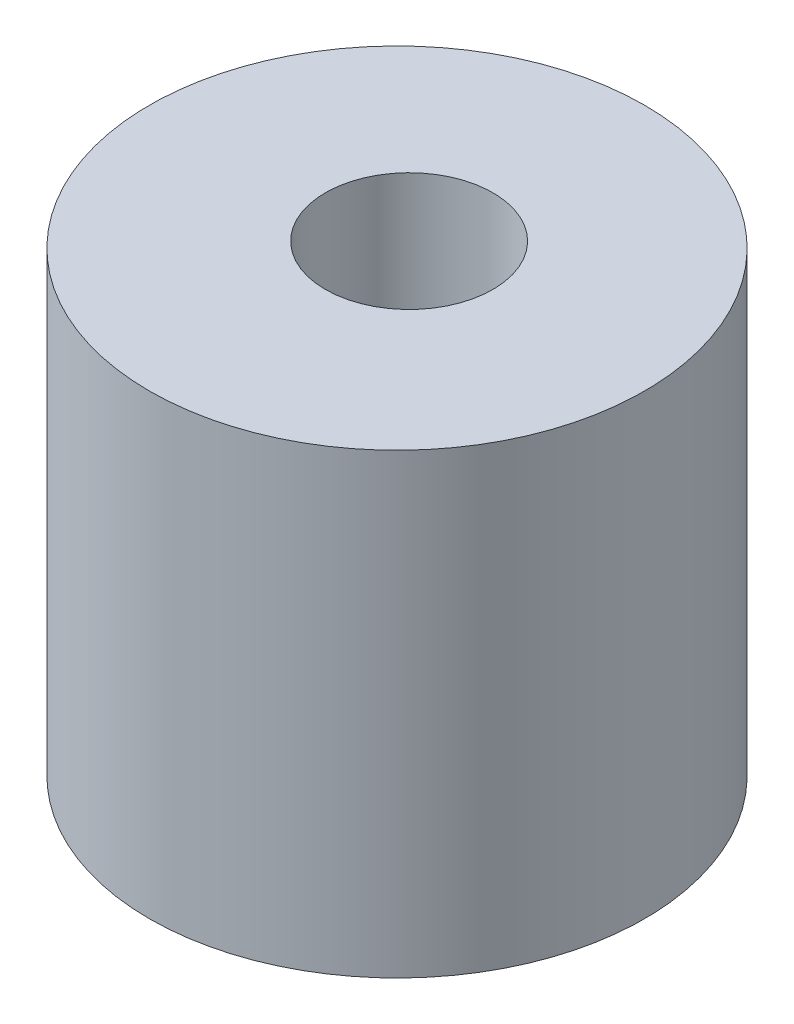
from build123d import *

# Parameters (mm, degrees)
ESQUISSE1_R        = 3.25
ESQUISSE1_R_2      = 1.1
BOSS_EXTRU_1_DEPTH = 6


with BuildPart() as part:
    # Esquisse1 → Boss.-Extru.1 (new body)
    with BuildSketch(Plane(origin=(0, 0, 0), x_dir=(1, 0, 0), z_dir=(0, 1, 0))):
        Circle(ESQUISSE1_R)
        with Locations((0, 0.159304864)):
            Circle(ESQUISSE1_R_2, mode=Mode.SUBTRACT)
    extrude(amount=BOSS_EXTRU_1_DEPTH)


solid = part.part
